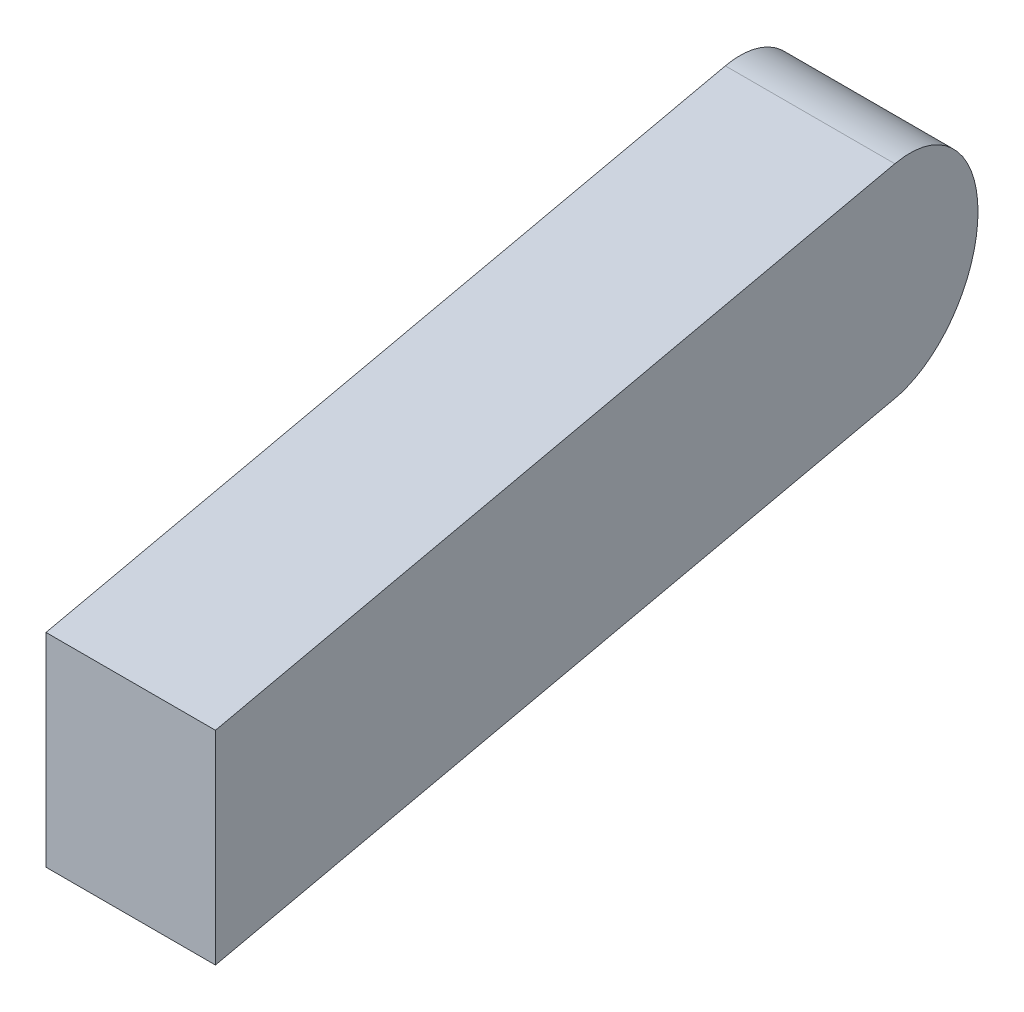
from build123d import *

# Parameters (mm, degrees)
BOSS_EXTRUDE1_DEPTH = 0.6
CUT_EXTRUDE1_DEPTH  = 6.622277119


with BuildPart() as part:
    # Sketch1 → Boss-Extrude1 (new, symmetric)
    with BuildSketch(Plane(origin=(0, 0, 0), x_dir=(1, 0, 0), z_dir=(0, 1, 0))):
        Polygon((0, 0), (1, 0), (0, 5.5), (-1, 5.5), align=None)
    extrude(amount=BOSS_EXTRUDE1_DEPTH, both=True)

    # Sketch4 → Cut-Extrude1 (cut, symmetric)
    with BuildSketch(Plane(origin=(0, 0, 0), x_dir=(0, 0, -1), z_dir=(1, 0, 0))):
        with BuildLine():
            Line((4.9, -0.6), (5.5, -0.6))
            Line((5.5, -0.6), (5.5, 0))
            ThreePointArc((5.5, 0), (5.324264069, -0.424264069), (4.9, -0.6))
        make_face()
    cut_extrude1 = extrude(amount=CUT_EXTRUDE1_DEPTH, both=True, mode=Mode.SUBTRACT)

    # Mirror1: Cut-Extrude1 across plane
    add(cut_extrude1.mirror(Plane.ZX), mode=Mode.SUBTRACT)


solid = part.part
